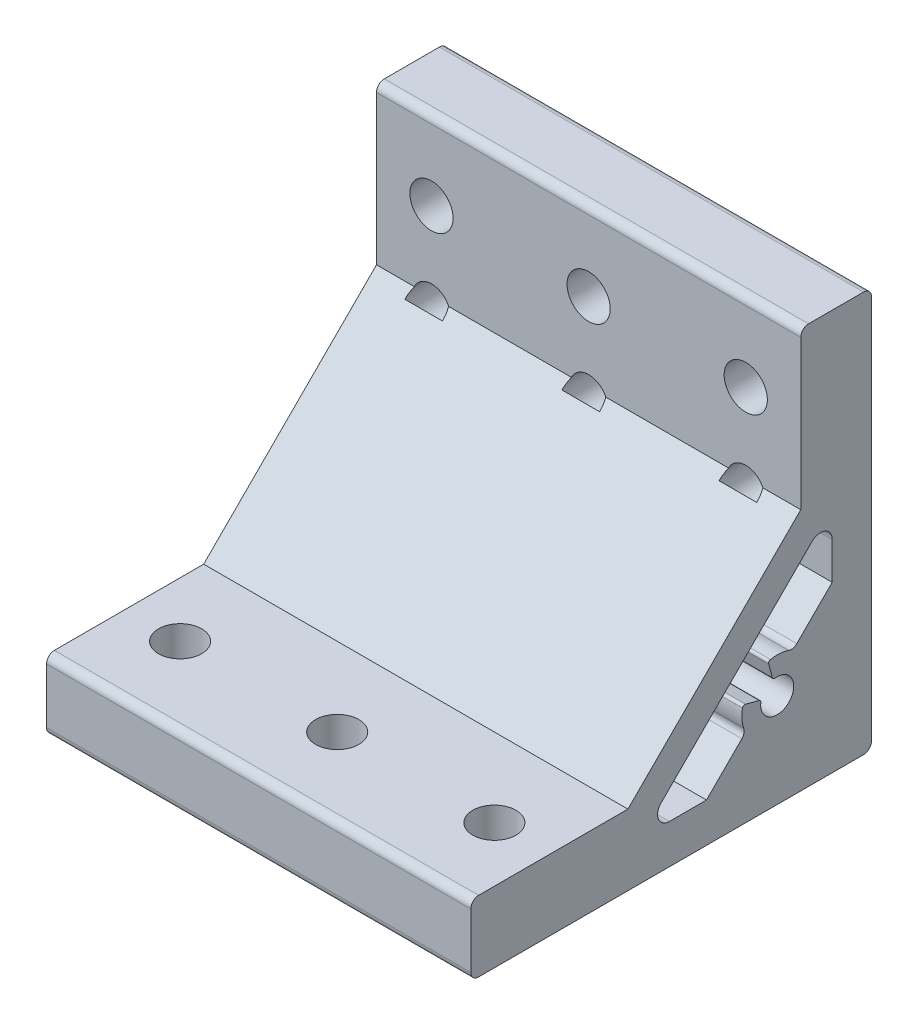
from build123d import *

# Parameters (mm, degrees)
BOSS_EXTRUDE1_DEPTH      = 27
BOSS_EXTRUDE1_DEPTH_BACK = 27
SKETCH6_R                = 2.75
CUT_EXTRUDE5_DEPTH       = 72.37226352
SKETCH7_R                = 2.75
CUT_EXTRUDE6_DEPTH       = 72.37226352
SKETCH9_R                = 2.4
CUT_EXTRUDE7_DEPTH       = 10


with BuildPart() as part:
    # Sketch1 → Boss-Extrude1 (new, two sides: drawn at the far end of the back side and taken through both)
    with BuildSketch(Plane(origin=(0, 0, 0), x_dir=(0, 0, -1), z_dir=(1, 0, 0)).offset(-BOSS_EXTRUDE1_DEPTH_BACK)):
        with BuildLine():
            Line((-50, 0), (-1, 0))
            ThreePointArc((-1, 0), (-0.292893219, 0.292893219), (0, 1))
            Line((0, 1), (0, 50))
            ThreePointArc((0, 50), (-0.292893219, 50.707106781), (-1, 51))
            Line((-1, 51), (-8, 51))
            ThreePointArc((-8, 51), (-8.707106781, 50.707106781), (-9, 50))
            Line((-9, 50), (-9, 31))
            Line((-9, 31), (-31, 9))
            Line((-31, 9), (-50, 9))
            ThreePointArc((-50, 9), (-50.707106781, 8.707106781), (-51, 8))
            Line((-51, 8), (-51, 1))
            ThreePointArc((-51, 1), (-50.707106781, 0.292893219), (-50, 0))
        make_face()
        with BuildLine():
            Line((-25.721825407, 5), (-20.999285733, 5))
            Line((-20.999285733, 5), (-16.494036438, 9.505249294))
            ThreePointArc((-16.494036438, 9.505249294), (-16.226979866, 9.987090789), (-16.255625497, 10.537245192))
            ThreePointArc((-16.255625497, 10.537245192), (-16.488859314, 11.683547702), (-16.418755424, 12.851234691))
            ThreePointArc((-16.418755424, 12.851234691), (-16.283360667, 13.048766752), (-16.046526031, 13.084263382))
            Line((-16.046526031, 13.084263382), (-14.300039569, 12.616293745))
            ThreePointArc((-14.300039569, 12.616293745), (-14.127781033, 12.492491496), (-14.080474622, 12.285701498))
            ThreePointArc((-14.080474622, 12.285701498), (-10.515075745, 10.515075774), (-12.285701539, 14.080474617))
            ThreePointArc((-12.285701539, 14.080474617), (-12.492491514, 14.127781045), (-12.616293745, 14.300039569))
            Line((-12.616293745, 14.300039569), (-13.084263382, 16.046526031))
            ThreePointArc((-13.084263382, 16.046526031), (-13.048766728, 16.283360705), (-12.851234602, 16.418755442))
            ThreePointArc((-12.851234602, 16.418755442), (-11.683774102, 16.488875269), (-10.537674556, 16.255773055))
            ThreePointArc((-10.537674556, 16.255773055), (-9.987311976, 16.226928716), (-9.505249294, 16.494036438))
            Line((-9.505249294, 16.494036438), (-5, 20.999285733))
            Line((-5, 20.999285733), (-5, 25.721825407))
            ThreePointArc((-5, 25.721825407), (-5.925974851, 27.107644706), (-7.560660172, 26.782485579))
            Line((-7.560660172, 26.782485579), (-26.782485579, 7.560660172))
            ThreePointArc((-26.782485579, 7.560660172), (-27.107644706, 5.925974851), (-25.721825407, 5))
        make_face(mode=Mode.SUBTRACT)
    extrude(amount=BOSS_EXTRUDE1_DEPTH + BOSS_EXTRUDE1_DEPTH_BACK)

    # Sketch6 → Cut-Extrude5 (cut, through all)
    with BuildSketch(Plane.XY.offset(9)):
        with Locations((-20, 41)):
            Circle(SKETCH6_R)
        with Locations((0, 41)):
            Circle(SKETCH6_R)
        with Locations((20, 41)):
            Circle(SKETCH6_R)
    extrude(amount=-CUT_EXTRUDE5_DEPTH, mode=Mode.SUBTRACT)

    # Sketch7 → Cut-Extrude6 (cut, through all)
    with BuildSketch(Plane(origin=(0, 9, 0), x_dir=(-1, 0, 0), z_dir=(0, 1, 0))):
        with Locations((20, 41)):
            Circle(SKETCH7_R)
        with Locations((0, 41)):
            Circle(SKETCH7_R)
        with Locations((-20, 41)):
            Circle(SKETCH7_R)
    extrude(amount=-CUT_EXTRUDE6_DEPTH, mode=Mode.SUBTRACT)

    # Sketch9 → Cut-Extrude7 (cut)
    with BuildSketch(Plane(origin=(0, 0, 0), x_dir=(-1, 0, 0), z_dir=(0, 0, -1))):
        with Locations((20, 30)):
            Circle(SKETCH9_R)
        with Locations((-20, 30)):
            Circle(SKETCH9_R)
        with Locations((0, 30)):
            Circle(SKETCH9_R)
    extrude(amount=-CUT_EXTRUDE7_DEPTH, mode=Mode.SUBTRACT)


solid = part.part
